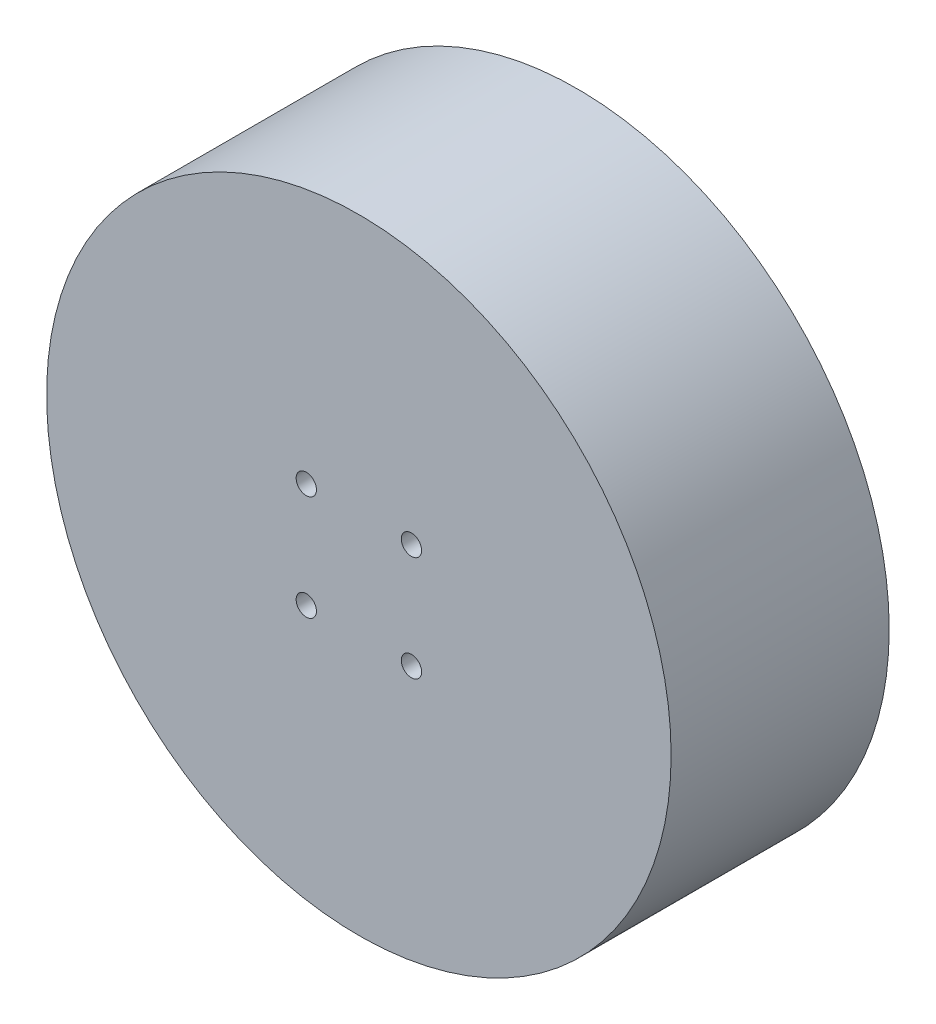
from build123d import *

# Parameters (mm, degrees)
SKETCH1_R                          = 31.5
BOSS_EXTRUDE1_DEPTH                = 22
TAP_DRILL_FOR_M2_5X0_45_TAP1_D     = 2.05
TAP_DRILL_FOR_M2_5X0_45_TAP1_DEPTH = 5.5
TAP_DRILL_FOR_M2_5X0_45_TAP1_TIP   = 0.615882135
TAP_DRILL_FOR_M3X0_5_TAP1_D        = 2.5
TAP_DRILL_FOR_M3X0_5_TAP1_DEPTH    = 5.5
TAP_DRILL_FOR_M3X0_5_TAP1_TIP      = 0.751075774


with BuildPart() as part:
    # Sketch1 → Boss-Extrude1 (new body)
    with BuildSketch(Plane.XY):
        Circle(SKETCH1_R)
    extrude(amount=BOSS_EXTRUDE1_DEPTH)

    # Tap Drill for M2.5x0.45 Tap1
    with Locations(Plane.XY.offset(22)):
        with Locations((-5.303300859, 5.303300859), (5.303300859, -5.303300859), (5.303300859, 5.303300859), (-5.303300859, -5.303300859)):
            Hole(TAP_DRILL_FOR_M2_5X0_45_TAP1_D / 2, depth=TAP_DRILL_FOR_M2_5X0_45_TAP1_DEPTH)
            with Locations((0, 0, -(TAP_DRILL_FOR_M2_5X0_45_TAP1_DEPTH + TAP_DRILL_FOR_M2_5X0_45_TAP1_TIP / 2))):  # 118° drill point
                Cone(0, TAP_DRILL_FOR_M2_5X0_45_TAP1_D / 2, TAP_DRILL_FOR_M2_5X0_45_TAP1_TIP, mode=Mode.SUBTRACT)

    # Tap Drill for M3x0.5 Tap1
    with Locations(Plane(origin=(0, 0, 0), x_dir=(-1, 0, 0), z_dir=(0, 0, -1))):
        with Locations((8.838834765, 8.838834765), (8.838834765, -8.838834765), (-8.838834765, 8.838834765), (-8.838834765, -8.838834765)):
            Hole(TAP_DRILL_FOR_M3X0_5_TAP1_D / 2, depth=TAP_DRILL_FOR_M3X0_5_TAP1_DEPTH)
            with Locations((0, 0, -(TAP_DRILL_FOR_M3X0_5_TAP1_DEPTH + TAP_DRILL_FOR_M3X0_5_TAP1_TIP / 2))):  # 118° drill point
                Cone(0, TAP_DRILL_FOR_M3X0_5_TAP1_D / 2, TAP_DRILL_FOR_M3X0_5_TAP1_TIP, mode=Mode.SUBTRACT)


solid = part.part
